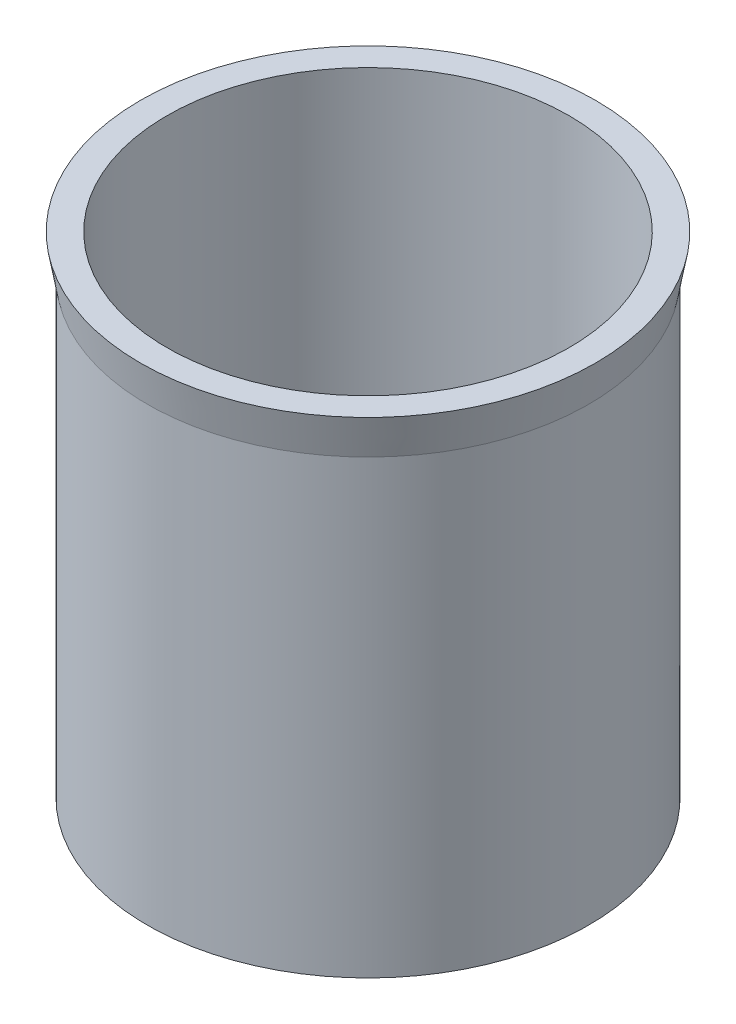
from build123d import *


with BuildPart() as part:
    # Sketch1 → Revolve1 (revolve)
    with BuildSketch(Plane.XY):
        Polygon((41, 0), (45, 0), (46.410615846, 0), (45, -8), (45, -100), (43.644904711, -100), (41, -85), align=None)
    revolve(axis=Axis((0, 0, 0), (0, 1, 0)))


solid = part.part
